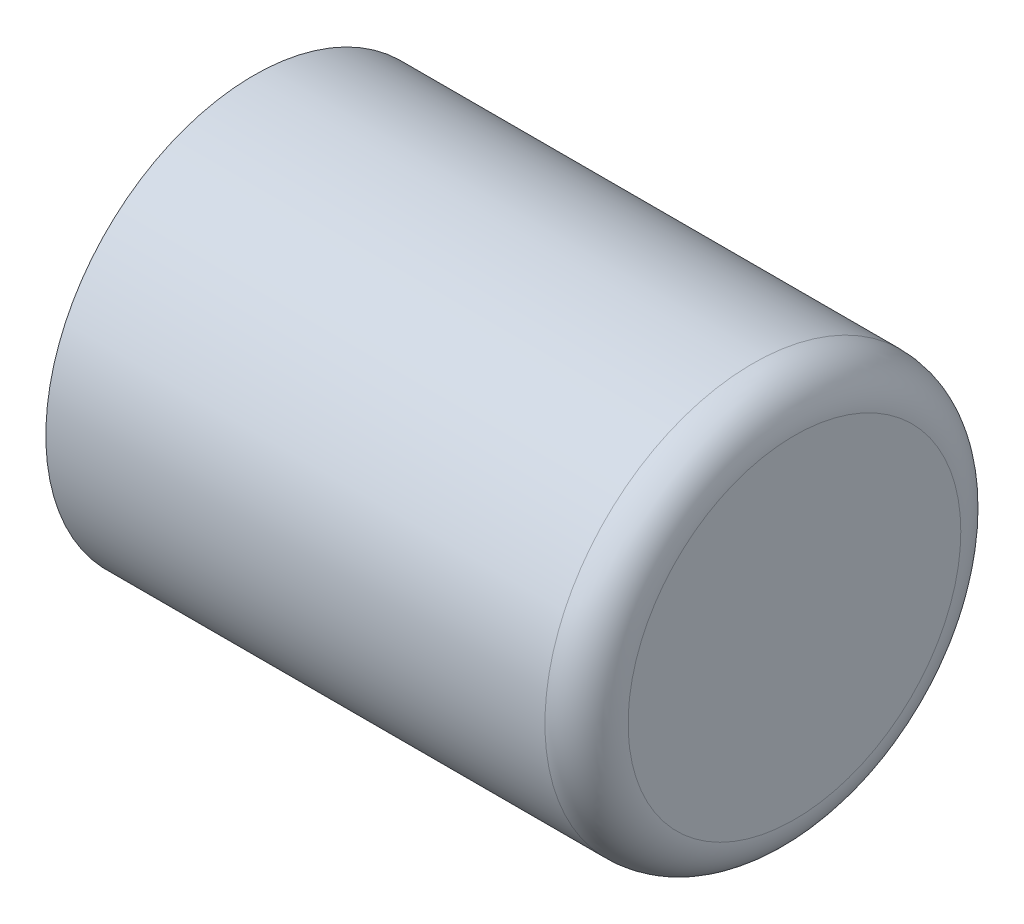
from build123d import *

# Parameters (mm, degrees)
SKETCH1_R           = 5
SKETCH1_R_2         = 2.5
BOSS_EXTRUDE1_DEPTH = 12
SKETCH2_R           = 5
BOSS_EXTRUDE2_DEPTH = 1
FILLET1_R           = 1


with BuildPart() as part:
    # Sketch1 → Boss-Extrude1 (new body)
    with BuildSketch(Plane(origin=(0, 0, 0), x_dir=(0, 0, -1), z_dir=(1, 0, 0))):
        Circle(SKETCH1_R)
        Circle(SKETCH1_R_2, mode=Mode.SUBTRACT)
    extrude(amount=BOSS_EXTRUDE1_DEPTH)

    # Sketch2 → Boss-Extrude2 (add)
    with BuildSketch(Plane(origin=(12, 0, 0), x_dir=(0, 0, -1), z_dir=(1, 0, 0))):
        Circle(SKETCH2_R)
    extrude(amount=BOSS_EXTRUDE2_DEPTH)

    # Fillet1
    fillet1_edges = [part.edges().sort_by_distance(p)[0] for p in [
        (13, 0, 5),
    ]]
    fillet(fillet1_edges, radius=FILLET1_R)


solid = part.part
